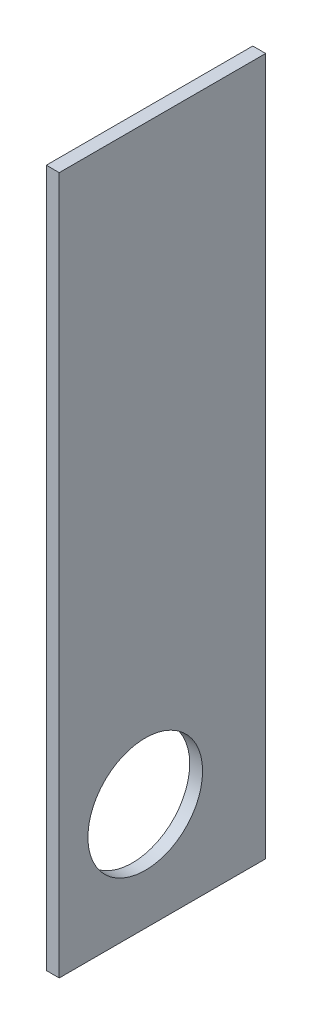
from build123d import *

# Parameters (mm, degrees)
SKETCH1_R           = 80
BOSS_EXTRUDE1_DEPTH = 18


with BuildPart() as part:
    # Sketch1 → Boss-Extrude1 (new body)
    with BuildSketch(Plane(origin=(0, 0, 0), x_dir=(0, 0, -1), z_dir=(1, 0, 0))):
        Polygon((20.392066811, -915.219556499), (-267.607933189, -915.219556499), (-267.607933189, -836.121901092), (-267.607933189, -676.121901092), (-267.607933189, 57.780443501), (20.392066811, 57.780443501), align=None)
        with Locations((-147.607933189, -765.219556499)):
            Circle(SKETCH1_R, mode=Mode.SUBTRACT)
    extrude(amount=BOSS_EXTRUDE1_DEPTH)


solid = part.part
